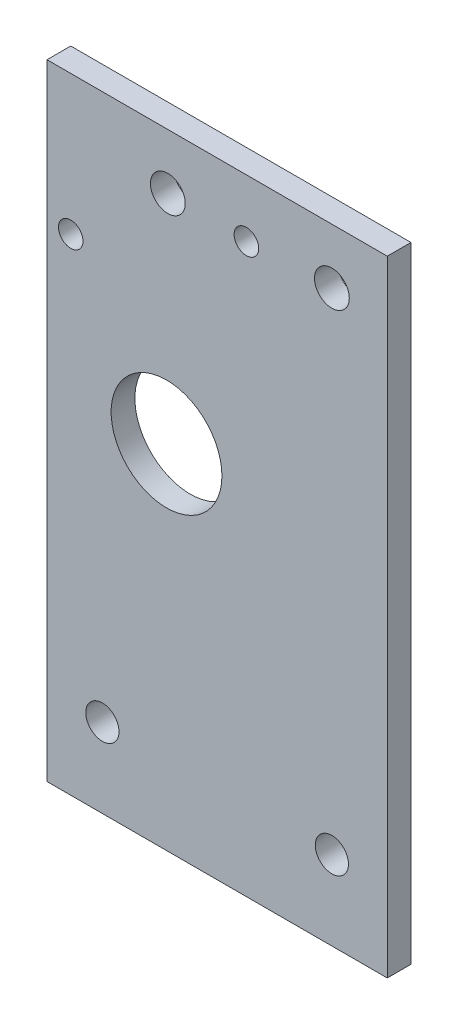
from build123d import *

# Parameters (mm, degrees)
SKETCH_1_W                = 40
SKETCH_1_H                = 29
EXTRUDE_1_DEPTH           = 3
CUT_EXTRUDE_1_DEPTH       = 3
SKETCH_3_W                = 40
SKETCH_3_H                = 3
EXTRUDE_2_DEPTH           = 10
SKETCH_4_W                = 40
SKETCH_4_H                = 3
EXTRUDE_3_DEPTH           = 10
SKETCH_6_W                = 3
SKETCH_6_H                = 49
EXTRUDE_5_DEPTH           = 42
SKETCH_8_W                = 3
SKETCH_8_H                = 49
EXTRUDE_6_DEPTH           = 2
SKETCH_9_W                = 3
SKETCH_9_H                = 49
EXTRUDE_7_DEPTH           = 2
SKETCH_10_W               = 86
SKETCH_10_H               = 3
EXTRUDE_8_DEPTH           = 10
SKETCH_11_W               = 86
SKETCH_11_H               = 3
EXTRUDE_9_DEPTH           = 10
SKETCH_7_R                = 7
CUT_EXTRUDE_4_DEPTH       = 10
SKETCH_14_W               = 3
SKETCH_14_H               = 69
CUT_EXTRUDE_5_DEPTH       = 43
SKETCH_17_W               = 43
SKETCH_17_H               = 3
EXTRUDE_10_DEPTH          = 20
SKETCH_18_R               = 2.1
CUT_EXTRUDE_6_DEPTH       = 10
SKETCH_20_W               = 43
SKETCH_20_H               = 3
EXTRUDE_11_DEPTH          = 10
SKETCH_21_W               = 43
SKETCH_21_H               = 3
CUT_EXTRUDE_7_DEPTH       = 20
SKETCH_24_R               = 2.2
CUT_EXTRUDE_8_DEPTH       = 30
SKETCH_25_R               = 1.55
CUT_EXTRUDE_11_DEPTH      = 1
CUT_EXTRUDE_11_DEPTH_BACK = 4


with BuildPart() as part:
    # ｽｹｯﾁ1 → ﾎﾞｽ - 押し出し1 (new body)
    with BuildSketch(Plane.XY):
        Rectangle(SKETCH_1_W, SKETCH_1_H)
    extrude(amount=EXTRUDE_1_DEPTH)

    # ｽｹｯﾁ2 → ｶｯﾄ - 押し出し1 (cut)
    with BuildSketch(Plane.XY.offset(3)):
        with BuildLine():
            ThreePointArc((-14.4, 10.5), (-15.01507576, 11.98492424), (-16.5, 12.6))
            Line((-16.5, 12.6), (-16.5, 10.5))
            Line((-16.5, 10.5), (-18.6, 10.5))
            ThreePointArc((-18.6, 10.5), (-16.5, 8.4), (-14.4, 10.5))
        make_face()
        with BuildLine():
            Line((-16.5, 10.5), (-16.5, 12.6))
            ThreePointArc((-16.5, 12.6), (-17.98492424, 11.98492424), (-18.6, 10.5))
            Line((-18.6, 10.5), (-16.5, 10.5))
        make_face()
        with BuildLine():
            ThreePointArc((-18.6, -10.5), (-17.98492424, -11.98492424), (-16.5, -12.6))
            Line((-16.5, -12.6), (-16.5, -10.5))
            Line((-16.5, -10.5), (-18.6, -10.5))
        make_face()
        with BuildLine():
            Line((-16.5, -10.5), (-16.5, -12.6))
            ThreePointArc((-16.5, -12.6), (-15.01507576, -11.98492424), (-14.4, -10.5))
            ThreePointArc((-14.4, -10.5), (-16.5, -8.4), (-18.6, -10.5))
            Line((-18.6, -10.5), (-16.5, -10.5))
        make_face()
        with BuildLine():
            ThreePointArc((18.6, -10.5), (15.01507576, -9.01507576), (16.5, -12.6))
            Line((16.5, -12.6), (16.5, -10.5))
            Line((16.5, -10.5), (18.6, -10.5))
        make_face()
        with BuildLine():
            Line((16.5, -10.5), (16.5, -12.6))
            ThreePointArc((16.5, -12.6), (17.98492424, -11.98492424), (18.6, -10.5))
            Line((18.6, -10.5), (16.5, -10.5))
        make_face()
        with BuildLine():
            ThreePointArc((18.6, 10.5), (17.98492424, 11.98492424), (16.5, 12.6))
            Line((16.5, 12.6), (16.5, 10.5))
            Line((16.5, 10.5), (18.6, 10.5))
        make_face()
        with BuildLine():
            Line((16.5, 10.5), (16.5, 12.6))
            ThreePointArc((16.5, 12.6), (15.01507576, 9.01507576), (18.6, 10.5))
            Line((18.6, 10.5), (16.5, 10.5))
        make_face()
    extrude(amount=-CUT_EXTRUDE_1_DEPTH, mode=Mode.SUBTRACT)

    # ｽｹｯﾁ3 → ﾎﾞｽ - 押し出し2 (add)
    with BuildSketch(Plane.XZ.offset(14.5)):
        with Locations((0, 1.5)):
            Rectangle(SKETCH_3_W, SKETCH_3_H)
    extrude(amount=EXTRUDE_2_DEPTH)

    # ｽｹｯﾁ4 → ﾎﾞｽ - 押し出し3 (add)
    with BuildSketch(Plane(origin=(0, 14.5, 0), x_dir=(1, 0, 0), z_dir=(0, 1, 0))):
        with Locations((0, -1.5)):
            Rectangle(SKETCH_4_W, SKETCH_4_H)
    extrude(amount=EXTRUDE_3_DEPTH)

    # ｽｹｯﾁ6 → ﾎﾞｽ - 押し出し5 (add)
    with BuildSketch(Plane(origin=(20, 0, 0), x_dir=(0, 0, -1), z_dir=(1, 0, 0))):
        with Locations((-1.5, 0)):
            Rectangle(SKETCH_6_W, SKETCH_6_H)
    extrude(amount=EXTRUDE_5_DEPTH)

    # ｽｹｯﾁ8 → ﾎﾞｽ - 押し出し6 (add)
    with BuildSketch(Plane.ZY.offset(20)):
        with Locations((1.5, 0)):
            Rectangle(SKETCH_8_W, SKETCH_8_H)
    extrude(amount=EXTRUDE_6_DEPTH)

    # ｽｹｯﾁ9 → ﾎﾞｽ - 押し出し7 (add)
    with BuildSketch(Plane(origin=(62, 0, 0), x_dir=(0, 0, -1), z_dir=(1, 0, 0))):
        with Locations((-1.5, 0)):
            Rectangle(SKETCH_9_W, SKETCH_9_H)
    extrude(amount=EXTRUDE_7_DEPTH)

    # ｽｹｯﾁ10 → ﾎﾞｽ - 押し出し8 (add)
    with BuildSketch(Plane.XZ.offset(24.5)):
        with Locations((21, 1.5)):
            Rectangle(SKETCH_10_W, SKETCH_10_H)
    extrude(amount=EXTRUDE_8_DEPTH)

    # ｽｹｯﾁ11 → ﾎﾞｽ - 押し出し9 (add)
    with BuildSketch(Plane(origin=(0, 24.5, 0), x_dir=(1, 0, 0), z_dir=(0, 1, 0))):
        with Locations((21, -1.5)):
            Rectangle(SKETCH_11_W, SKETCH_11_H)
    extrude(amount=EXTRUDE_9_DEPTH)

    # ｽｹｯﾁ7 → ｶｯﾄ - 押し出し4 (cut)
    with BuildSketch(Plane.XY.offset(3)):
        with Locations((36.10579786, 0)):
            Circle(SKETCH_7_R)
    extrude(amount=-CUT_EXTRUDE_4_DEPTH, mode=Mode.SUBTRACT)

    # ｽｹｯﾁ14 → ｶｯﾄ - 押し出し5 (cut)
    with BuildSketch(Plane.ZY.offset(22)):
        with Locations((1.5, 0)):
            Rectangle(SKETCH_14_W, SKETCH_14_H)
    extrude(amount=-CUT_EXTRUDE_5_DEPTH, mode=Mode.SUBTRACT)

    # ｽｹｯﾁ17 → ﾎﾞｽ - 押し出し10 (add)
    with BuildSketch(Plane.XZ.offset(34.5)):
        with Locations((42.5, 1.5)):
            Rectangle(SKETCH_17_W, SKETCH_17_H)
    extrude(amount=EXTRUDE_10_DEPTH)

    # ｽｹｯﾁ18 → ｶｯﾄ - 押し出し6 (cut)
    with BuildSketch(Plane.XY.offset(3)):
        with Locations((28, -34.5)):
            Circle(SKETCH_18_R)
        with Locations((57, -34.5)):
            Circle(SKETCH_18_R)
    extrude(amount=-CUT_EXTRUDE_6_DEPTH, mode=Mode.SUBTRACT)

    # ｽｹｯﾁ20 → ﾎﾞｽ - 押し出し11 (add)
    with BuildSketch(Plane.XZ.offset(54.5)):
        with Locations((42.5, 1.5)):
            Rectangle(SKETCH_20_W, SKETCH_20_H)
    extrude(amount=EXTRUDE_11_DEPTH)

    # ｽｹｯﾁ21 → ｶｯﾄ - 押し出し7 (cut)
    with BuildSketch(Plane.XZ.offset(64.5)):
        with Locations((42.5, 1.5)):
            Rectangle(SKETCH_21_W, SKETCH_21_H)
    extrude(amount=-CUT_EXTRUDE_7_DEPTH, mode=Mode.SUBTRACT)

    # ｽｹｯﾁ24 → ｶｯﾄ - 押し出し8 (cut)
    with BuildSketch(Plane(origin=(0, 0, 0), x_dir=(-1, 0, 0), z_dir=(0, 0, -1))):
        with Locations((-36.27, 27.5)):
            Circle(SKETCH_24_R)
        with Locations((-57, 27.5)):
            Circle(SKETCH_24_R)
    extrude(amount=-CUT_EXTRUDE_8_DEPTH, mode=Mode.SUBTRACT)

    # ｽｹｯﾁ25 → ｶｯﾄ - 押し出し11 (cut, two sides)
    with BuildSketch(Plane(origin=(0, 0, 0), x_dir=(-1, 0, 0), z_dir=(0, 0, -1))) as cut_extrude_11_sk:
        with Locations((-24, 16.905537109)):
            Circle(SKETCH_25_R)
        with Locations((-46.2, 27.205537109)):
            Circle(SKETCH_25_R)
    extrude(amount=CUT_EXTRUDE_11_DEPTH, mode=Mode.SUBTRACT)
    extrude(cut_extrude_11_sk.sketch, amount=-CUT_EXTRUDE_11_DEPTH_BACK, mode=Mode.SUBTRACT)


solid = part.part
